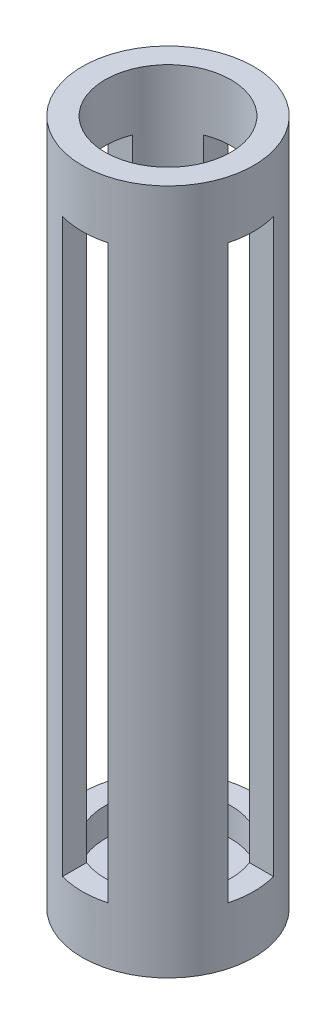
from build123d import *

# Parameters (mm, degrees)
SKETCH1_R               = 19.05
SKETCH1_R_2             = 13.97
BOSS_EXTRUDE1_DEPTH     = 152.4
SKETCH2_R               = 13.97
BOSS_EXTRUDE2_DEPTH     = 6.35
SKETCH3_R               = 2.2479
CUT_EXTRUDE1_DEPTH      = 3.54
CUT_EXTRUDE1_DEPTH_BACK = 36.56
SKETCH5_W               = 10.16
SKETCH5_H               = 127
CUT_EXTRUDE5_DEPTH      = 20.0500001
CUT_EXTRUDE5_DEPTH_BACK = 20.0500001
SKETCH8_W               = 10.16
SKETCH8_H               = 127
CUT_EXTRUDE6_DEPTH      = 20.050000101
CUT_EXTRUDE6_DEPTH_BACK = 20.050000101
SKETCH7_R               = 6.35
CUT_EXTRUDE4_DEPTH      = 7.35
BOSS_EXTRUDE3_DEPTH     = 2.54


with BuildPart() as part:
    # Sketch1 → Boss-Extrude1 (new body)
    with BuildSketch(Plane(origin=(0, 0, 0), x_dir=(1, 0, 0), z_dir=(0, 1, 0))):
        Circle(SKETCH1_R)
        Circle(SKETCH1_R_2, mode=Mode.SUBTRACT)
    extrude(amount=BOSS_EXTRUDE1_DEPTH)

    # Sketch2 → Boss-Extrude2 (add)
    with BuildSketch(Plane.XZ):
        Circle(SKETCH2_R)
    extrude(amount=-BOSS_EXTRUDE2_DEPTH)

    # Sketch3 → Cut-Extrude1 (cut, two sides)
    with BuildSketch(Plane.XY.offset(16.51)) as cut_extrude1_sk:
        with Locations((0, 101.6)):
            Circle(SKETCH3_R)
    extrude(amount=CUT_EXTRUDE1_DEPTH, mode=Mode.SUBTRACT)
    extrude(cut_extrude1_sk.sketch, amount=-CUT_EXTRUDE1_DEPTH_BACK, mode=Mode.SUBTRACT)

    # Sketch5 → Cut-Extrude5 (cut, two sides)
    with BuildSketch(Plane(origin=(0, 0, 0), x_dir=(0, 0, -1), z_dir=(1, 0, 0))) as cut_extrude5_sk:
        with Locations((0, 76.2)):
            Rectangle(SKETCH5_W, SKETCH5_H)
    extrude(amount=CUT_EXTRUDE5_DEPTH, mode=Mode.SUBTRACT)
    extrude(cut_extrude5_sk.sketch, amount=-CUT_EXTRUDE5_DEPTH_BACK, mode=Mode.SUBTRACT)

    # Sketch8 → Cut-Extrude6 (cut, two sides)
    with BuildSketch(Plane.XY) as cut_extrude6_sk:
        with Locations((0, 76.2)):
            Rectangle(SKETCH8_W, SKETCH8_H)
    extrude(amount=CUT_EXTRUDE6_DEPTH, mode=Mode.SUBTRACT)
    extrude(cut_extrude6_sk.sketch, amount=-CUT_EXTRUDE6_DEPTH_BACK, mode=Mode.SUBTRACT)

    # Sketch7 → Cut-Extrude4 (cut, through all)
    with BuildSketch(Plane(origin=(0, 6.35, 0), x_dir=(1, 0, 0), z_dir=(0, 1, 0))):
        Circle(SKETCH7_R)
    extrude(amount=-CUT_EXTRUDE4_DEPTH, mode=Mode.SUBTRACT)

    # Sketch9 → Boss-Extrude3 (add)
    with BuildSketch(Plane(origin=(0, 45.72, 0), x_dir=(-1, 0, 0), z_dir=(0, -1, 0))):
        with BuildLine():
            Line((-11.787736325, -7.497344352), (-8.572899145, -5.452614074))
            ThreePointArc((-8.572899145, -5.452614074), (-6.7552586, -7.588944673), (-4.422740729, -9.14685544))
            Line((-4.422740729, -9.14685544), (-6.081268502, -12.57692623))
            ThreePointArc((-6.081268502, -12.57692623), (-9.288480575, -10.434798925), (-11.787736325, -7.497344352))
        make_face()
        with BuildLine():
            Line((11.787736325, 7.497344352), (8.572899145, 5.452614074))
            ThreePointArc((8.572899145, 5.452614074), (6.7552586, 7.588944673), (4.422740729, 9.14685544))
            Line((4.422740729, 9.14685544), (6.081268502, 12.57692623))
            ThreePointArc((6.081268502, 12.57692623), (9.288480575, 10.434798925), (11.787736325, 7.497344352))
        make_face()
    extrude(amount=-BOSS_EXTRUDE3_DEPTH)


solid = part.part
